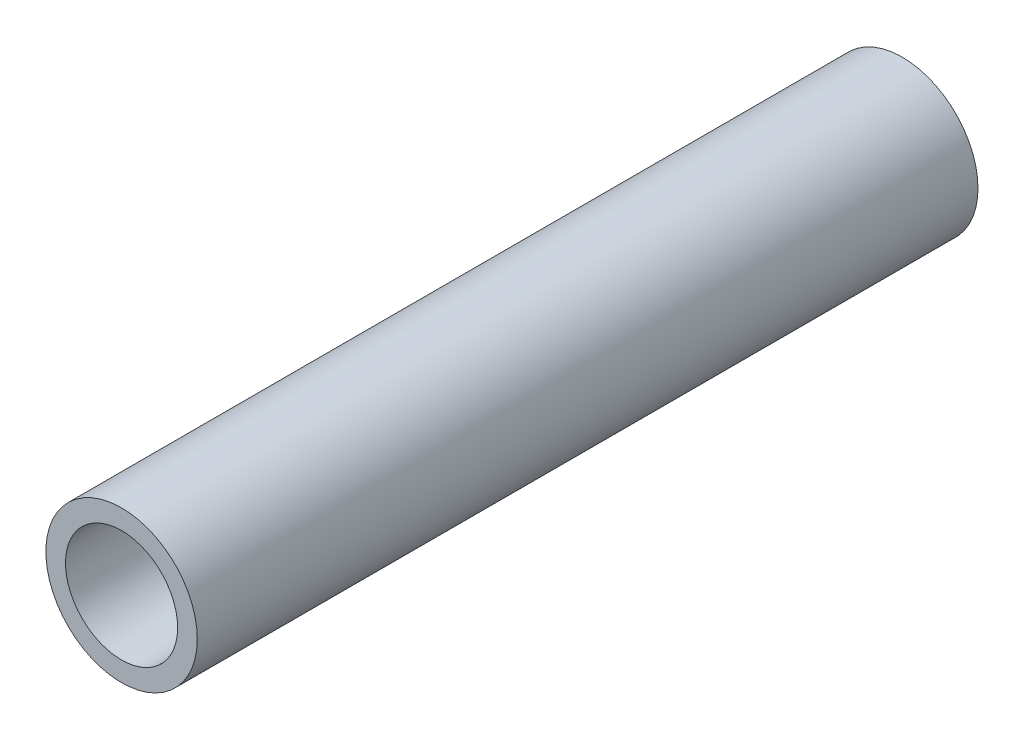
from build123d import *

# Parameters (mm, degrees)
SKETCH1_R           = 10.668
SKETCH1_R_2         = 7.8994
EXTRUDE_THIN1_DEPTH = 55


with BuildPart() as part:
    # Sketch1 → Extrude-Thin1 (new body, symmetric)
    with BuildSketch(Plane.XY):
        Circle(SKETCH1_R)
        Circle(SKETCH1_R_2, mode=Mode.SUBTRACT)
    extrude(amount=EXTRUDE_THIN1_DEPTH, both=True)


solid = part.part
